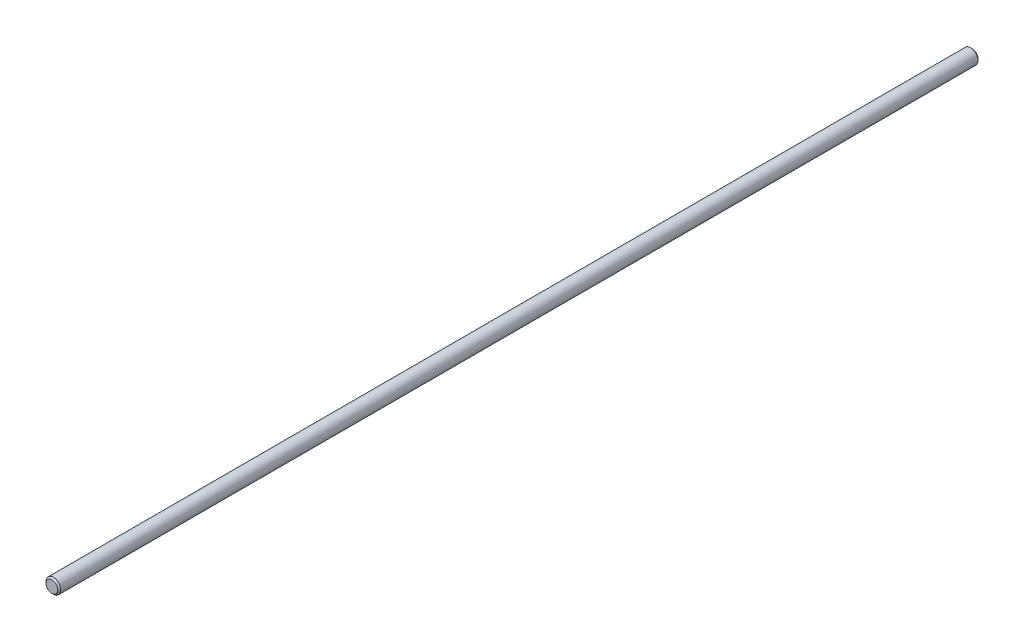
from build123d import *

# Parameters (mm, degrees)
SKETCH1_R      = 8
EXTRUDE1_DEPTH = 500
CHAMFER1_SIZE  = 1.6


with BuildPart() as part:
    # Sketch1 → Extrude1 (new body, symmetric)
    with BuildSketch(Plane.XY):
        Circle(SKETCH1_R)
    extrude(amount=EXTRUDE1_DEPTH, both=True)

    # Chamfer1
    chamfer1_edges = [part.edges().sort_by_distance(p)[0] for p in [
        (-8, 0, -500),
        (-8, 0, 500),
    ]]
    chamfer(chamfer1_edges, length=CHAMFER1_SIZE)


solid = part.part
